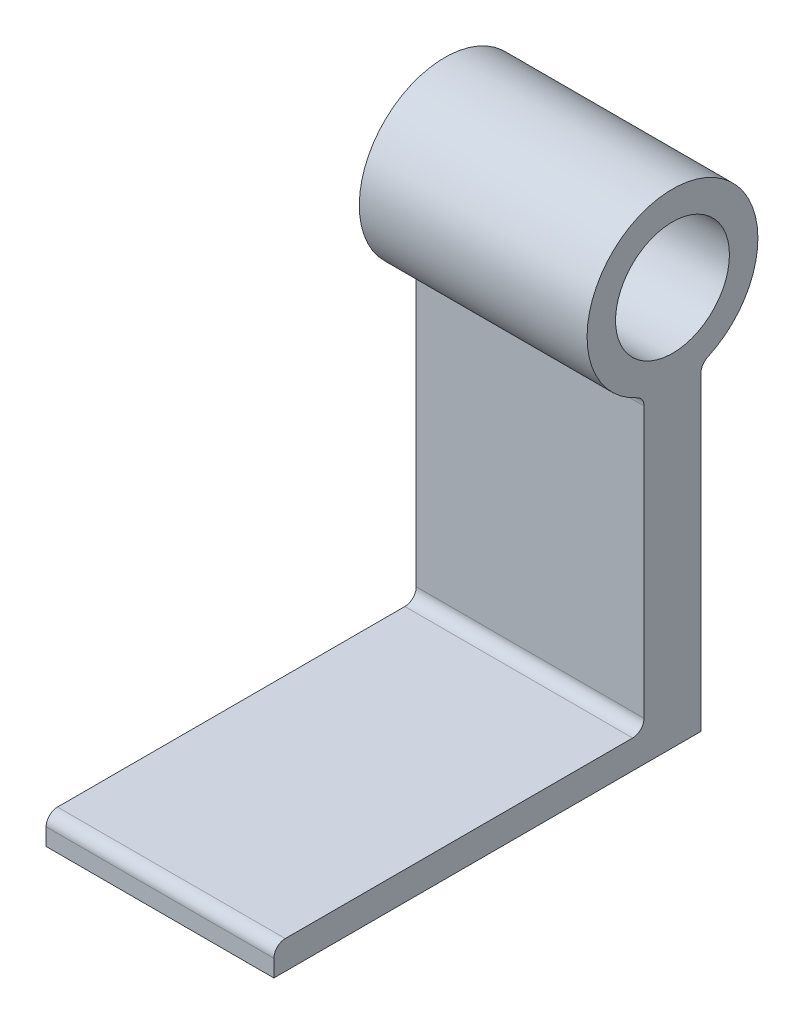
from build123d import *

# Parameters (mm, degrees)
SKETCH1_R           = 12.7
BOSS_EXTRUDE1_DEPTH = 50.8
FILLET1_R           = 2.54
FILLET2_R           = 2.54


with BuildPart() as part:
    # Sketch1 → Boss-Extrude1 (new body)
    with BuildSketch(Plane(origin=(0, 0, 0), x_dir=(0, 0, -1), z_dir=(1, 0, 0))):
        with BuildLine():
            Line((-95.25, 0), (0, 0))
            Line((0, 0), (0, 70.939487758))
            ThreePointArc((0, 70.939487758), (-6.35, 69.85), (-12.7, 70.939487758))
            Line((-12.7, 70.939487758), (-12.7, 6.35))
            Line((-12.7, 6.35), (-95.25, 6.35))
            Line((-95.25, 6.35), (-95.25, 0))
        make_face()
        with BuildLine():
            Line((-12.7, 70.939487758), (0, 70.939487758))
            ThreePointArc((0, 70.939487758), (9.204259867, 77.901477372), (12.7, 88.9))
            ThreePointArc((12.7, 88.9), (-17.348522628, 104.454259867), (-12.7, 70.939487758))
        make_face()
        with Locations((-6.35, 88.9)):
            Circle(SKETCH1_R, mode=Mode.SUBTRACT)
        with BuildLine():
            ThreePointArc((-12.7, 70.939487758), (-6.35, 69.85), (0, 70.939487758))
            Line((0, 70.939487758), (-12.7, 70.939487758))
        make_face()
    extrude(amount=BOSS_EXTRUDE1_DEPTH)

    # Fillet1
    fillet1_edges = [part.edges().sort_by_distance(p)[0] for p in [
        (25.4, 6.35, 12.7),
        (25.4, 70.939487758, 12.7),
        (25.4, 70.939487758, 0),
    ]]
    fillet(fillet1_edges, radius=FILLET1_R)

    # Fillet2
    fillet2_edges = [part.edges().sort_by_distance(p)[0] for p in [
        (25.4, 6.35, 95.25),
    ]]
    fillet(fillet2_edges, radius=FILLET2_R)


solid = part.part
